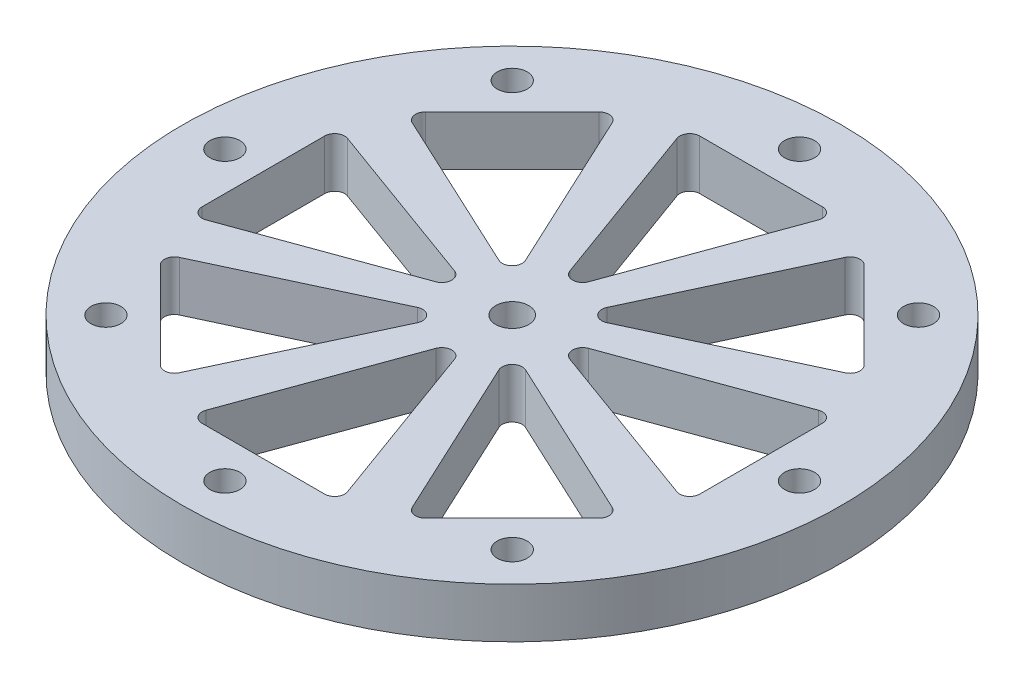
from build123d import *

# Parameters (mm, degrees)
SKETCH1_R           = 33
SKETCH1_R_2         = 1.65
BOSS_EXTRUDE1_DEPTH = 5
CUT_EXTRUDE2_DEPTH  = 6
SKETCH3_R           = 1.5
CUT_EXTRUDE3_DEPTH  = 6


with BuildPart() as part:
    # Sketch1 → Boss-Extrude1 (new body)
    with BuildSketch(Plane(origin=(0, 0, 0), x_dir=(1, 0, 0), z_dir=(0, 1, 0))):
        with Locations((0, -0.021032705)):
            Circle(SKETCH1_R)
        Circle(SKETCH1_R_2, mode=Mode.SUBTRACT)
    extrude(amount=BOSS_EXTRUDE1_DEPTH)

    # Sketch2 → Cut-Extrude2 (cut, through all)
    with BuildSketch(Plane(origin=(0, 5, 0), x_dir=(1, 0, 0), z_dir=(0, 1, 0))):
        with BuildLine():
            ThreePointArc((-7.078024727, 23.574927841), (-6.957484151, 24.490524421), (-6.138332106, 24.916947985))
            Line((-6.138332106, 24.916947985), (6.138332106, 24.916947985))
            ThreePointArc((6.138332106, 24.916947985), (6.957484151, 24.490524421), (7.078024727, 23.574927841))
            Line((7.078024727, 23.574927841), (0.939692621, 6.709998986))
            ThreePointArc((0.939692621, 6.709998986), (0, 6.052019129), (-0.939692621, 6.709998986))
            Line((-0.939692621, 6.709998986), (-7.078024727, 23.574927841))
        make_face()
        with BuildLine():
            Line((4.08022276, 5.409148809), (11.665072061, 21.674910625))
            ThreePointArc((11.665072061, 21.674910625), (12.39773167, 22.237100116), (13.278486629, 21.959399144))
            Line((13.278486629, 21.959399144), (21.959399144, 13.278486629))
            ThreePointArc((21.959399144, 13.278486629), (22.237100116, 12.39773167), (21.674910625, 11.665072061))
            Line((21.674910625, 11.665072061), (5.409148809, 4.08022276))
            ThreePointArc((5.409148809, 4.08022276), (4.279423766, 4.279423766), (4.08022276, 5.409148809))
        make_face()
        with BuildLine():
            Line((6.709998986, 0.939692621), (23.574927841, 7.078024727))
            ThreePointArc((23.574927841, 7.078024727), (24.490524421, 6.957484151), (24.916947985, 6.138332106))
            Line((24.916947985, 6.138332106), (24.916947985, -6.138332106))
            ThreePointArc((24.916947985, -6.138332106), (24.490524421, -6.957484151), (23.574927841, -7.078024727))
            Line((23.574927841, -7.078024727), (6.709998986, -0.939692621))
            ThreePointArc((6.709998986, -0.939692621), (6.052019129, 0), (6.709998986, 0.939692621))
        make_face()
        with BuildLine():
            Line((5.409148809, -4.08022276), (21.674910625, -11.665072061))
            ThreePointArc((21.674910625, -11.665072061), (22.237100116, -12.39773167), (21.959399144, -13.278486629))
            Line((21.959399144, -13.278486629), (13.278486629, -21.959399144))
            ThreePointArc((13.278486629, -21.959399144), (12.39773167, -22.237100116), (11.665072061, -21.674910625))
            Line((11.665072061, -21.674910625), (4.08022276, -5.409148809))
            ThreePointArc((4.08022276, -5.409148809), (4.279423766, -4.279423766), (5.409148809, -4.08022276))
        make_face()
        with BuildLine():
            Line((0.939692621, -6.709998986), (7.078024727, -23.574927841))
            ThreePointArc((7.078024727, -23.574927841), (6.957484151, -24.490524421), (6.138332106, -24.916947985))
            Line((6.138332106, -24.916947985), (-6.138332106, -24.916947985))
            ThreePointArc((-6.138332106, -24.916947985), (-6.957484151, -24.490524421), (-7.078024727, -23.574927841))
            Line((-7.078024727, -23.574927841), (-0.939692621, -6.709998986))
            ThreePointArc((-0.939692621, -6.709998986), (0, -6.052019129), (0.939692621, -6.709998986))
        make_face()
        with BuildLine():
            Line((-4.08022276, -5.409148809), (-11.665072061, -21.674910625))
            ThreePointArc((-11.665072061, -21.674910625), (-12.39773167, -22.237100116), (-13.278486629, -21.959399144))
            Line((-13.278486629, -21.959399144), (-21.959399144, -13.278486629))
            ThreePointArc((-21.959399144, -13.278486629), (-22.237100116, -12.39773167), (-21.674910625, -11.665072061))
            Line((-21.674910625, -11.665072061), (-5.409148809, -4.08022276))
            ThreePointArc((-5.409148809, -4.08022276), (-4.279423766, -4.279423766), (-4.08022276, -5.409148809))
        make_face()
        with BuildLine():
            Line((-6.709998986, -0.939692621), (-23.574927841, -7.078024727))
            ThreePointArc((-23.574927841, -7.078024727), (-24.490524421, -6.957484151), (-24.916947985, -6.138332106))
            Line((-24.916947985, -6.138332106), (-24.916947985, 6.138332106))
            ThreePointArc((-24.916947985, 6.138332106), (-24.490524421, 6.957484151), (-23.574927841, 7.078024727))
            Line((-23.574927841, 7.078024727), (-6.709998986, 0.939692621))
            ThreePointArc((-6.709998986, 0.939692621), (-6.052019129, 0), (-6.709998986, -0.939692621))
        make_face()
        with BuildLine():
            Line((-5.409148809, 4.08022276), (-21.674910625, 11.665072061))
            ThreePointArc((-21.674910625, 11.665072061), (-22.237100116, 12.39773167), (-21.959399144, 13.278486629))
            Line((-21.959399144, 13.278486629), (-13.278486629, 21.959399144))
            ThreePointArc((-13.278486629, 21.959399144), (-12.39773167, 22.237100116), (-11.665072061, 21.674910625))
            Line((-11.665072061, 21.674910625), (-4.08022276, 5.409148809))
            ThreePointArc((-4.08022276, 5.409148809), (-4.279423766, 4.279423766), (-5.409148809, 4.08022276))
        make_face()
    extrude(amount=-CUT_EXTRUDE2_DEPTH, mode=Mode.SUBTRACT)

    # Sketch3 → Cut-Extrude3 (cut, through all)
    with BuildSketch(Plane(origin=(0, 5, 0), x_dir=(1, 0, 0), z_dir=(0, 1, 0))):
        with Locations((0, 28.769709793)):
            Circle(SKETCH3_R)
        with Locations((20.343256888, 20.343256888)):
            Circle(SKETCH3_R)
        with Locations((28.769709793, 0)):
            Circle(SKETCH3_R)
        with Locations((20.343256888, -20.343256888)):
            Circle(SKETCH3_R)
        with Locations((0, -28.769709793)):
            Circle(SKETCH3_R)
        with Locations((-20.343256888, -20.343256888)):
            Circle(SKETCH3_R)
        with Locations((-28.769709793, 0)):
            Circle(SKETCH3_R)
        with Locations((-20.343256888, 20.343256888)):
            Circle(SKETCH3_R)
    extrude(amount=-CUT_EXTRUDE3_DEPTH, mode=Mode.SUBTRACT)


solid = part.part
